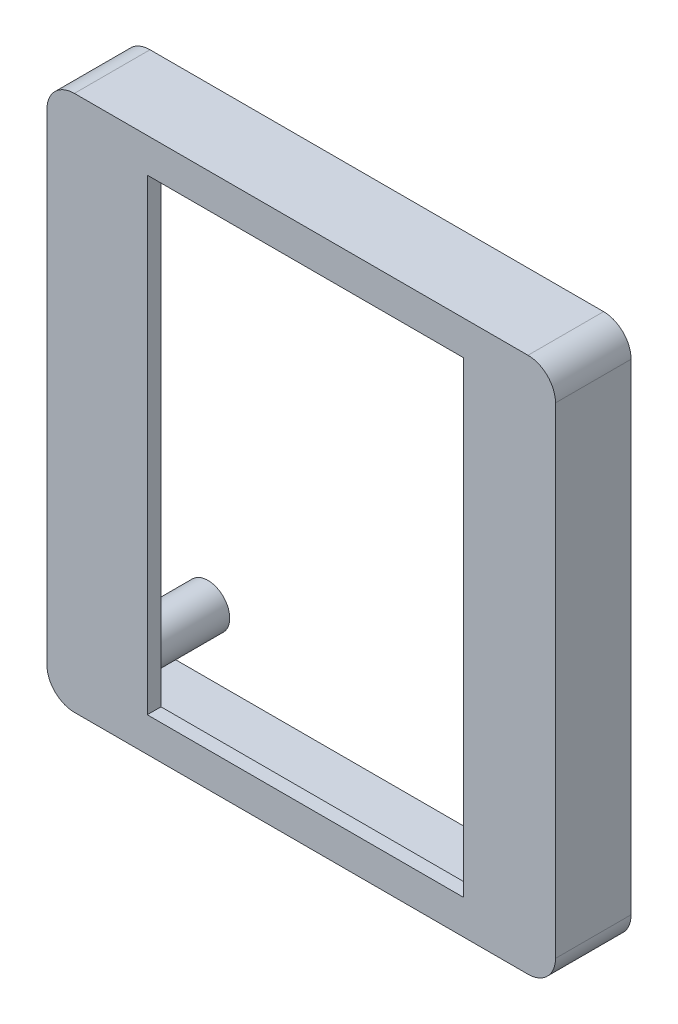
from build123d import *

# Parameters (mm, degrees)
CROQUIS1_R                = 1.5875
SALIENTE_EXTRUIR1_DEPTH   = 6.5
SALIENTE_EXTRUIR1_2_DEPTH = 6.5
SALIENTE_EXTRUIR1_3_DEPTH = 6.5
SALIENTE_EXTRUIR1_4_DEPTH = 6.5
SALIENTE_EXTRUIR2_DEPTH   = 4.5
CROQUIS3_W                = 23
CROQUIS3_H                = 34
SALIENTE_EXTRUIR3_DEPTH   = 1


with BuildPart() as part:
    # Croquis1 → Saliente-Extruir1 (new body)
    with BuildSketch(Plane.XY):
        with Locations((14.790535489, 1.2625)):
            Circle(CROQUIS1_R)
    extrude(amount=SALIENTE_EXTRUIR1_DEPTH)



with BuildPart() as body_2:
    # Croquis1 → Saliente-Extruir1 2 (new body)
    with BuildSketch(Plane.XY):
        with Locations((14.790535489, -29.5625)):
            Circle(CROQUIS1_R)
    extrude(amount=SALIENTE_EXTRUIR1_2_DEPTH)


with BuildPart() as body_3:
    # Croquis1 → Saliente-Extruir1 3 (new body)
    with BuildSketch(Plane.XY):
        with Locations((-13.784464511, -29.5625)):
            Circle(CROQUIS1_R)
    extrude(amount=SALIENTE_EXTRUIR1_3_DEPTH)


with BuildPart() as body_4:
    # Croquis1 → Saliente-Extruir1 4 (new body)
    with BuildSketch(Plane.XY):
        with Locations((-13.784464511, 1.2625)):
            Circle(CROQUIS1_R)
    extrude(amount=SALIENTE_EXTRUIR1_4_DEPTH)


with BuildPart() as body_5:
    # Croquis2 → Saliente-Extruir2 (new body)
    with BuildSketch(Plane.XY.offset(2)):
        with BuildLine():
            ThreePointArc((-15.996964511, 5.35), (-17.411178073, 4.764213562), (-17.996964511, 3.35))
            Line((-17.996964511, 3.35), (-17.996964511, -31.65))
            ThreePointArc((-17.996964511, -31.65), (-17.411178073, -33.064213562), (-15.996964511, -33.65))
            Line((-15.996964511, -33.65), (17.003035489, -33.65))
            ThreePointArc((17.003035489, -33.65), (18.417249051, -33.064213562), (19.003035489, -31.65))
            Line((19.003035489, -31.65), (19.003035489, 3.35))
            ThreePointArc((19.003035489, 3.35), (18.417249051, 4.764213562), (17.003035489, 5.35))
            Line((17.003035489, 5.35), (-15.996964511, 5.35))
        make_face()
        with BuildLine():
            Line((-16.496964511, -8.883114021), (-16.496964511, 3.85))
            Line((-16.496964511, 3.85), (17.503035489, 3.85))
            Line((17.503035489, 3.85), (17.503035489, -32.15))
            Line((17.503035489, -32.15), (-16.496964511, -32.15))
            Line((-16.496964511, -32.15), (-16.496964511, -19.416885979))
            ThreePointArc((-16.496964511, -19.416885979), (-16.73791903, -18.965158785), (-16.821172495, -18.46))
            Line((-16.821172495, -18.46), (-16.821172495, -9.84))
            ThreePointArc((-16.821172495, -9.84), (-16.73791903, -9.334841215), (-16.496964511, -8.883114021))
        make_face(mode=Mode.SUBTRACT)
    extrude(amount=SALIENTE_EXTRUIR2_DEPTH)


with BuildPart() as part_1:
    add(part.part)

    add(body_2.part)  # Saliente-Extruir3 merges body 2

    add(body_3.part)  # Saliente-Extruir3 merges body 3

    add(body_4.part)  # Saliente-Extruir3 merges body 4

    add(body_5.part)  # Saliente-Extruir3 merges body 5
    # Croquis3 → Saliente-Extruir3 (add)
    with BuildSketch(Plane.XY.offset(6.5)):
        with BuildLine():
            ThreePointArc((19.003035489, 3.35), (18.417249051, 4.764213562), (17.003035489, 5.35))
            Line((17.003035489, 5.35), (-15.996964511, 5.35))
            ThreePointArc((-15.996964511, 5.35), (-17.411178073, 4.764213562), (-17.996964511, 3.35))
            Line((-17.996964511, 3.35), (-17.996964511, -31.65))
            ThreePointArc((-17.996964511, -31.65), (-17.411178073, -33.064213562), (-15.996964511, -33.65))
            Line((-15.996964511, -33.65), (17.003035489, -33.65))
            ThreePointArc((17.003035489, -33.65), (18.417249051, -33.064213562), (19.003035489, -31.65))
            Line((19.003035489, -31.65), (19.003035489, 3.35))
        make_face()
        with BuildLine():
            ThreePointArc((-16.821172495, -9.84), (-16.73791903, -9.334841215), (-16.496964511, -8.883114021))
            Line((-16.496964511, -8.883114021), (-16.496964511, 3.85))
            Line((-16.496964511, 3.85), (17.503035489, 3.85))
            Line((17.503035489, 3.85), (17.503035489, -32.15))
            Line((17.503035489, -32.15), (-16.496964511, -32.15))
            Line((-16.496964511, -32.15), (-16.496964511, -19.416885979))
            ThreePointArc((-16.496964511, -19.416885979), (-16.73791903, -18.965158785), (-16.821172495, -18.46))
            Line((-16.821172495, -18.46), (-16.821172495, -9.84))
        make_face(mode=Mode.SUBTRACT)
        with BuildLine():
            Line((-16.496964511, -8.883114021), (-16.496964511, 3.85))
            Line((-16.496964511, 3.85), (17.503035489, 3.85))
            Line((17.503035489, 3.85), (17.503035489, -32.15))
            Line((17.503035489, -32.15), (-16.496964511, -32.15))
            Line((-16.496964511, -32.15), (-16.496964511, -19.416885979))
            ThreePointArc((-16.496964511, -19.416885979), (-16.73791903, -18.965158785), (-16.821172495, -18.46))
            Line((-16.821172495, -18.46), (-16.821172495, -9.84))
            ThreePointArc((-16.821172495, -9.84), (-16.73791903, -9.334841215), (-16.496964511, -8.883114021))
        make_face()
        with Locations((0.803035489, -14.15)):
            Rectangle(CROQUIS3_W, CROQUIS3_H, mode=Mode.SUBTRACT)
    extrude(amount=SALIENTE_EXTRUIR3_DEPTH)


solid = part_1.part
